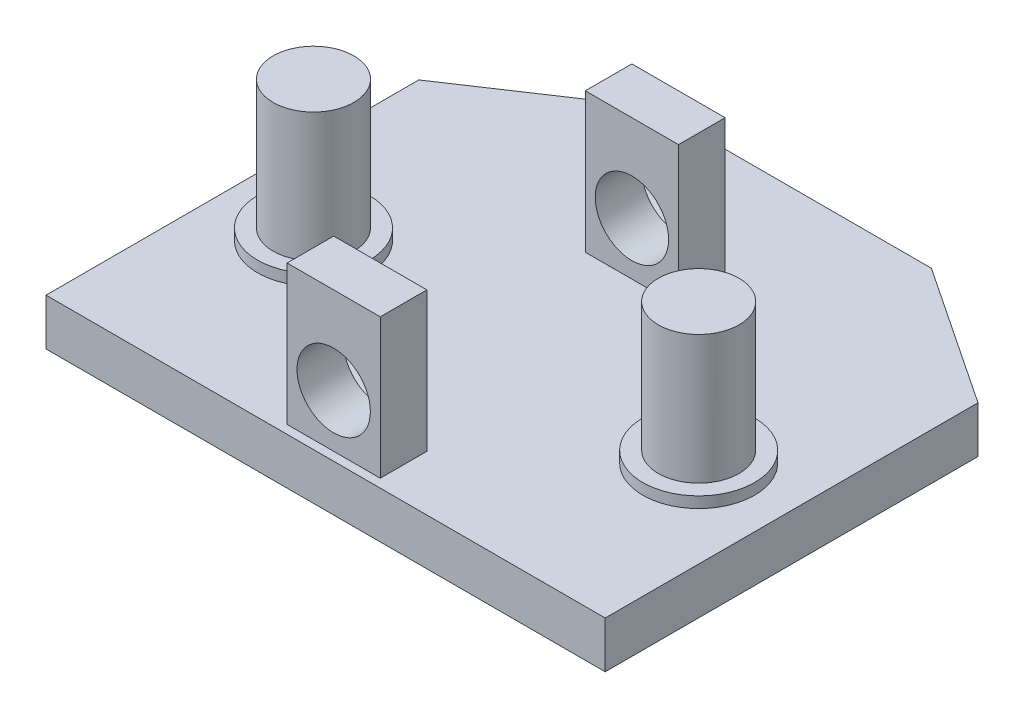
from build123d import *

# Parameters (mm, degrees)
BOSS_EXTRUDE1_DEPTH = 6.35
SKETCH3_W           = 12.7
SKETCH3_H           = 6.35
BOSS_EXTRUDE2_DEPTH = 19.05
SKETCH4_R           = 5
CUT_EXTRUDE1_DEPTH  = 12.7
LPATTERN1_COUNT     = 2
LPATTERN1_PITCH     = 40.64
SKETCH5_R           = 5.5
BOSS_EXTRUDE3_DEPTH = 19.05
SKETCH10_R          = 7.62
BOSS_EXTRUDE4_DEPTH = 1.5


with BuildPart() as part:
    # Sketch2 → Boss-Extrude1 (new body)
    with BuildSketch(Plane(origin=(0, 0, 0), x_dir=(1, 0, 0), z_dir=(0, 1, 0))):
        Polygon((-38.1, 0), (38.1, 0), (38.1, 50.8), (19.05, 63.5), (-19.05, 63.5), (-38.1, 50.8), align=None)
    extrude(amount=BOSS_EXTRUDE1_DEPTH)

    # Sketch3 → Boss-Extrude2 (add)
    with BuildSketch(Plane(origin=(0, 6.35, 0), x_dir=(1, 0, 0), z_dir=(0, 1, 0))):
        with Locations((-0.072298758, 4.346211763)):
            Rectangle(SKETCH3_W, SKETCH3_H)
    boss_extrude2 = extrude(amount=BOSS_EXTRUDE2_DEPTH)

    # Sketch4 → Cut-Extrude1 (cut)
    with BuildSketch(Plane.XY.offset(-1.171211763)):
        with Locations((-0.072298758, 13.524669763)):
            Circle(SKETCH4_R)
    cut_extrude1 = extrude(amount=-CUT_EXTRUDE1_DEPTH, mode=Mode.SUBTRACT)

    # LPattern1: Boss-Extrude2, Cut-Extrude1 ×2
    with Locations(*[(0, 0, -i * LPATTERN1_PITCH) for i in range(1, LPATTERN1_COUNT)]):
        add(boss_extrude2)
        add(cut_extrude1, mode=Mode.SUBTRACT)

    # Sketch5 → Boss-Extrude3 (add)
    with BuildSketch(Plane(origin=(0, 6.35, 0), x_dir=(1, 0, 0), z_dir=(0, 1, 0))):
        with Locations((-26.317835068, 24.666211763)):
            Circle(SKETCH5_R)
        with Locations((26.173237553, 24.666211763)):
            Circle(SKETCH5_R)
    extrude(amount=BOSS_EXTRUDE3_DEPTH)

    # Sketch10 → Boss-Extrude4 (add)
    with BuildSketch(Plane(origin=(0, 6.35, 0), x_dir=(1, 0, 0), z_dir=(0, 1, 0))):
        with Locations((-26.31783504, 24.666211763)):
            Circle(SKETCH10_R)
        with Locations((26.173237524, 24.666211763)):
            Circle(SKETCH10_R)
    extrude(amount=BOSS_EXTRUDE4_DEPTH)


solid = part.part
